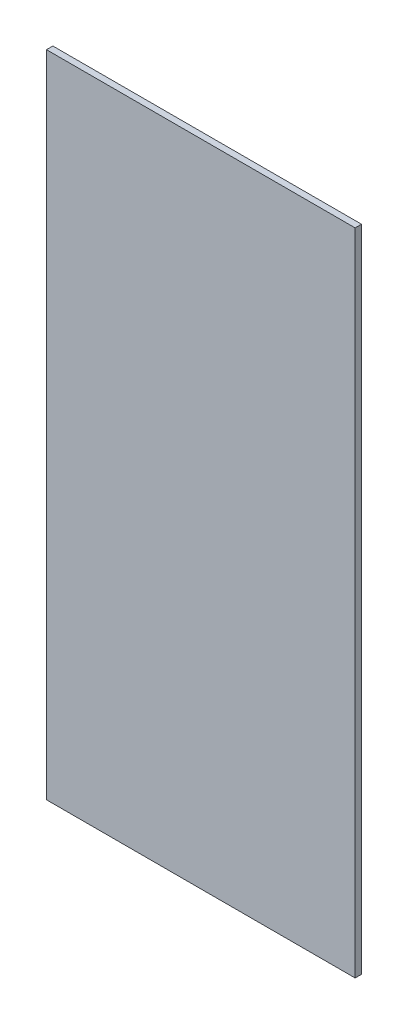
from build123d import *

# Parameters (mm, degrees)
SKETCH1_W           = 576.2625
SKETCH1_H           = 1212.85
BOSS_EXTRUDE1_DEPTH = 11.90625


with BuildPart() as part:
    # Sketch1 → Boss-Extrude1 (new body)
    with BuildSketch(Plane.XY):
        with Locations((153.934696394, -238.465786271)):
            Rectangle(SKETCH1_W, SKETCH1_H)
    extrude(amount=BOSS_EXTRUDE1_DEPTH)


solid = part.part
